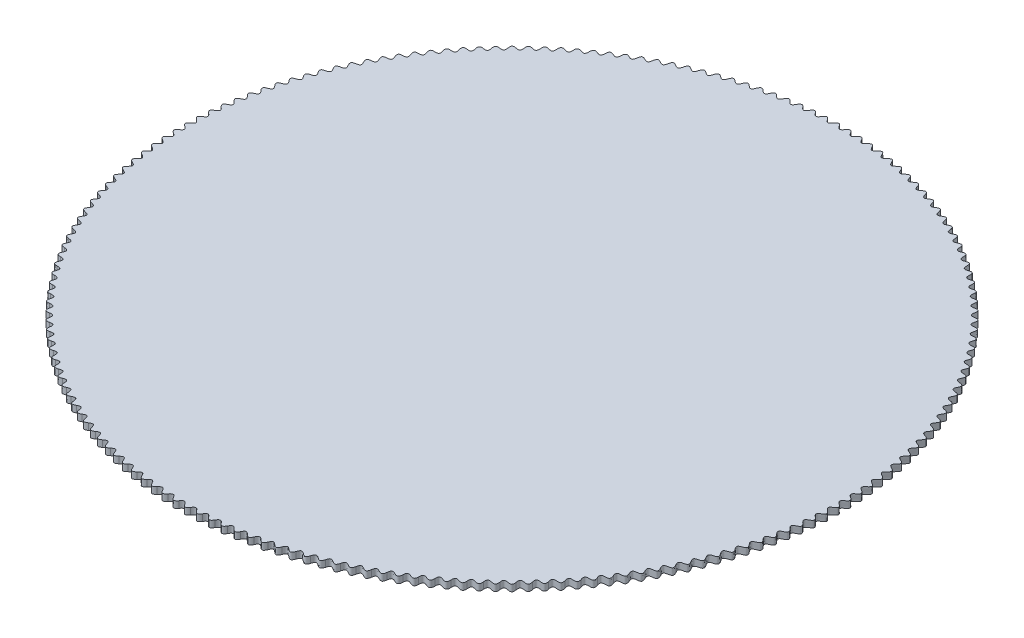
from build123d import *

# Parameters (mm, degrees)
SKIZZE1_R                       = 50
AUFSATZ_LINEAR_AUSTRAGEN1_DEPTH = 1
SCHNITT_LINEAR_AUSTRAGEN1_DEPTH = 2
KREISMUSTER1_COUNT              = 178


with BuildPart() as part:
    # Skizze1 → Aufsatz-Linear austragen1 (new body)
    with BuildSketch(Plane(origin=(0, 0, 0), x_dir=(1, 0, 0), z_dir=(0, 1, 0))):
        with Locations(Location((0, 0, 0), (0, 0, 270))):  # turned: the seam where the file's is
            Circle(SKIZZE1_R)
    extrude(amount=AUFSATZ_LINEAR_AUSTRAGEN1_DEPTH)

    # Skizze2 → Schnitt-Linear austragen1 (cut, through all)
    with BuildSketch(Plane(origin=(0, 1, 0), x_dir=(1, 0, 0), z_dir=(0, 1, 0))):
        with BuildLine():
            Line((-0.873735873, 49.5), (-0.882561488, 50))
            Line((-0.882561488, 50), (0.882561488, 50))
            Line((0.882561488, 50), (0.873735873, 49.5))
            add(Edge.make_bspline(
                [(-0.873735873, 49.5), (0, 50.75), (0, 48.25), (0.873735873, 49.5)],
                knots=[0, 0, 0, 0, 1, 1, 1, 1], degree=3))
        make_face()
    schnitt_linear_austragen1 = extrude(amount=-SCHNITT_LINEAR_AUSTRAGEN1_DEPTH, mode=Mode.SUBTRACT)

    # Kreismuster1: Schnitt-Linear austragen1 ×178 about axis
    kreismuster1_axis = Axis((0, 1, 0), (0, 1, 0))
    for i in range(1, KREISMUSTER1_COUNT):
        add(schnitt_linear_austragen1.rotate(kreismuster1_axis, i * 360 / KREISMUSTER1_COUNT), mode=Mode.SUBTRACT)


solid = part.part
